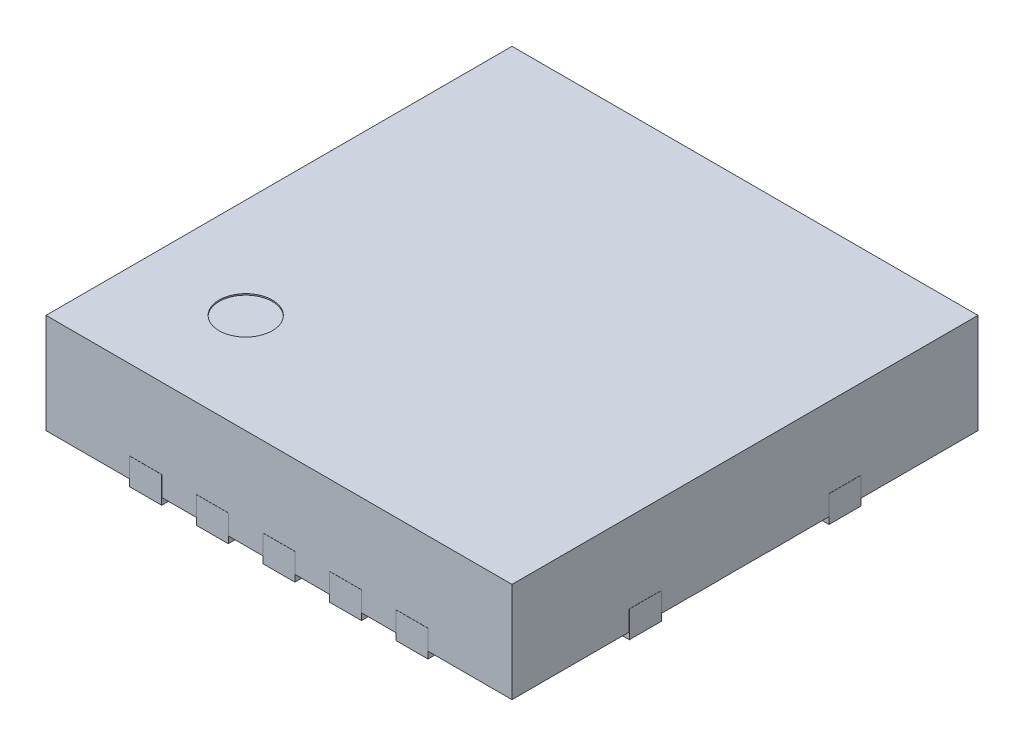
from build123d import *

# Parameters (mm, degrees)
SKETCH1_W                = 3.5
SKETCH1_H                = 3.5
BOSS_EXTRUDE1_DEPTH      = 0.75
SKETCH2_R                = 0.2
CUT_EXTRUDE1_DEPTH       = 0.01
BOSS_EXTRUDE2_DEPTH      = 0.05
BOSS_EXTRUDE2_DEPTH_BACK = 0.15
BOSS_EXTRUDE3_DEPTH      = 0.001


with BuildPart() as part:
    # Sketch1 → Boss-Extrude1 (new body)
    with BuildSketch(Plane(origin=(0, 0, 0), x_dir=(1, 0, 0), z_dir=(0, 1, 0))):
        Rectangle(SKETCH1_W, SKETCH1_H)
    extrude(amount=BOSS_EXTRUDE1_DEPTH)

    # Sketch2 → Cut-Extrude1 (cut)
    with BuildSketch(Plane(origin=(0, 0.75, 0), x_dir=(1, 0, 0), z_dir=(0, 1, 0))):
        with Locations((-1, -1)):
            Circle(SKETCH2_R)
    extrude(amount=-CUT_EXTRUDE1_DEPTH, mode=Mode.SUBTRACT)

    # Sketch3 → Boss-Extrude2 (add, two sides)
    with BuildSketch(Plane.XZ) as boss_extrude2_sk:
        with BuildLine():
            Line((-1.12, 1.751), (-0.88, 1.751))
            Line((-0.88, 1.751), (-0.88, 1.471))
            ThreePointArc((-0.88, 1.471), (-1, 1.351), (-1.12, 1.471))
            Line((-1.12, 1.471), (-1.12, 1.751))
        make_face()
        with BuildLine():
            Line((-1.751, 0.63), (-1.751, 0.87))
            Line((-1.751, 0.87), (-1.471, 0.87))
            ThreePointArc((-1.471, 0.87), (-1.351, 0.75), (-1.471, 0.63))
            Line((-1.471, 0.63), (-1.751, 0.63))
        make_face()
        with BuildLine():
            Line((-0.62, 1.751), (-0.62, 1.471))
            ThreePointArc((-0.62, 1.471), (-0.5, 1.351), (-0.38, 1.471))
            Line((-0.38, 1.471), (-0.38, 1.751))
            Line((-0.38, 1.751), (-0.62, 1.751))
        make_face()
        with BuildLine():
            Line((-0.12, 1.751), (-0.12, 1.471))
            ThreePointArc((-0.12, 1.471), (0, 1.351), (0.12, 1.471))
            Line((0.12, 1.471), (0.12, 1.751))
            Line((0.12, 1.751), (-0.12, 1.751))
        make_face()
        with BuildLine():
            Line((0.38, 1.751), (0.38, 1.471))
            ThreePointArc((0.38, 1.471), (0.5, 1.351), (0.62, 1.471))
            Line((0.62, 1.471), (0.62, 1.751))
            Line((0.62, 1.751), (0.38, 1.751))
        make_face()
        with BuildLine():
            Line((0.88, 1.751), (0.88, 1.471))
            ThreePointArc((0.88, 1.471), (1, 1.351), (1.12, 1.471))
            Line((1.12, 1.471), (1.12, 1.751))
            Line((1.12, 1.751), (0.88, 1.751))
        make_face()
        with BuildLine():
            Line((1.751, -0.63), (1.751, -0.87))
            Line((1.751, -0.87), (1.471, -0.87))
            ThreePointArc((1.471, -0.87), (1.351, -0.75), (1.471, -0.63))
            Line((1.471, -0.63), (1.751, -0.63))
        make_face()
        with BuildLine():
            Line((0.88, -1.751), (1.12, -1.751))
            Line((1.12, -1.751), (1.12, -1.471))
            ThreePointArc((1.12, -1.471), (1, -1.351), (0.88, -1.471))
            Line((0.88, -1.471), (0.88, -1.751))
        make_face()
        with BuildLine():
            Line((0.38, -1.751), (0.62, -1.751))
            Line((0.62, -1.751), (0.62, -1.471))
            ThreePointArc((0.62, -1.471), (0.5, -1.351), (0.38, -1.471))
            Line((0.38, -1.471), (0.38, -1.751))
        make_face()
        with BuildLine():
            Line((-0.12, -1.751), (0.12, -1.751))
            Line((0.12, -1.751), (0.12, -1.471))
            ThreePointArc((0.12, -1.471), (0, -1.351), (-0.12, -1.471))
            Line((-0.12, -1.471), (-0.12, -1.751))
        make_face()
        with BuildLine():
            Line((-0.62, -1.751), (-0.38, -1.751))
            Line((-0.38, -1.751), (-0.38, -1.471))
            ThreePointArc((-0.38, -1.471), (-0.5, -1.351), (-0.62, -1.471))
            Line((-0.62, -1.471), (-0.62, -1.751))
        make_face()
        with BuildLine():
            Line((-1.751, -0.63), (-1.471, -0.63))
            ThreePointArc((-1.471, -0.63), (-1.351, -0.75), (-1.471, -0.87))
            Line((-1.471, -0.87), (-1.751, -0.87))
            Line((-1.751, -0.87), (-1.751, -0.63))
        make_face()
        with BuildLine():
            Line((-0.88, -1.751), (-0.88, -1.471))
            ThreePointArc((-0.88, -1.471), (-1, -1.351), (-1.12, -1.471))
            Line((-1.12, -1.471), (-1.12, -1.751))
            Line((-1.12, -1.751), (-0.88, -1.751))
        make_face()
        with BuildLine():
            Line((1.751, 0.63), (1.471, 0.63))
            ThreePointArc((1.471, 0.63), (1.351, 0.75), (1.471, 0.87))
            Line((1.471, 0.87), (1.751, 0.87))
            Line((1.751, 0.87), (1.751, 0.63))
        make_face()
    extrude(amount=BOSS_EXTRUDE2_DEPTH)
    extrude(boss_extrude2_sk.sketch, amount=-BOSS_EXTRUDE2_DEPTH_BACK)

    # Sketch4 → Boss-Extrude3 (add)
    with BuildSketch(Plane.XZ):
        Polygon((-1, 0.6), (-0.6, 1), (1, 1), (1, 0.375), (1.75, 0.375), (1.75, 0.175), (1.469620109, 0.175), (1.469620109, -0.175), (1.75, -0.175), (1.75, -0.375), (1, -0.375), (1, -1), (-1, -1), (-1, -0.375), (-1.75, -0.375), (-1.75, -0.175), (-1.469620109, -0.175), (-1.469620109, 0.175), (-1.75, 0.175), (-1.75, 0.375), (-1, 0.375), align=None)
    extrude(amount=BOSS_EXTRUDE3_DEPTH)


solid = part.part
